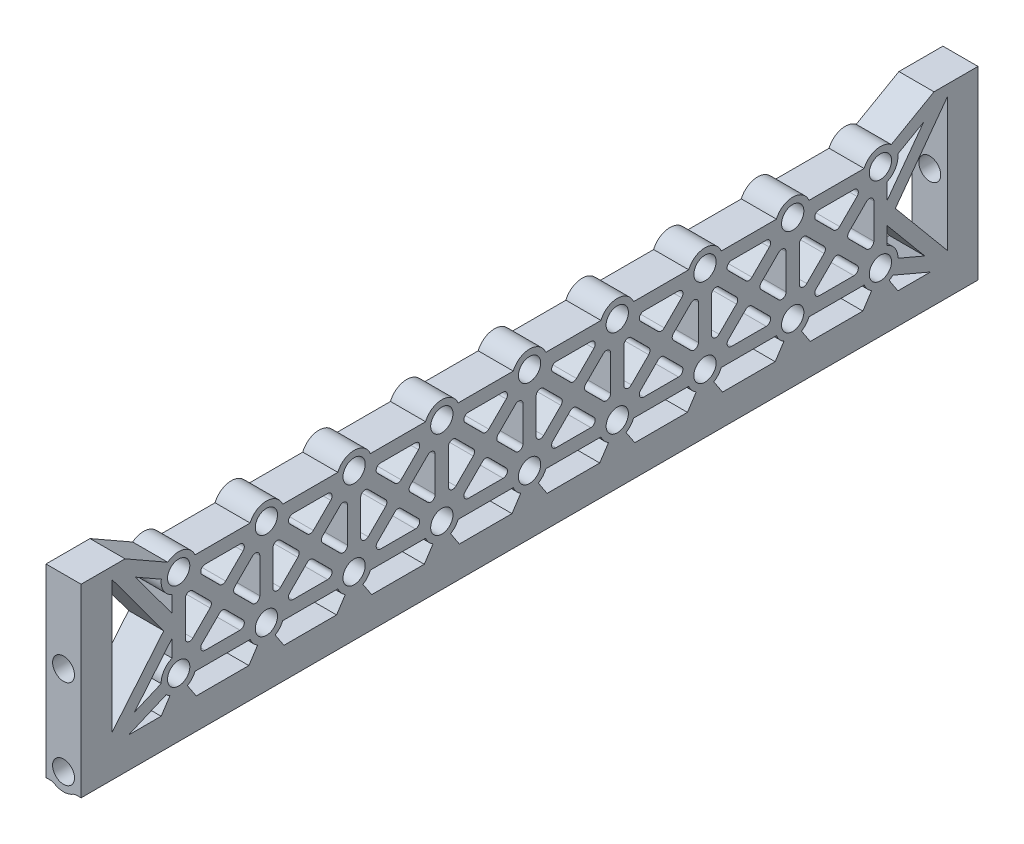
from build123d import *

# Parameters (mm, degrees)
SKETCH1_W                      = 204.5
SKETCH1_H                      = 42.185
BOSS_EXTRUDE1_DEPTH            = 8
F_5_0MM_DOWEL_HOLE1_AT_2_COUNT = 2
F_5_0MM_DOWEL_HOLE1_AT_2_PITCH = 20.325
SKETCH5_R                      = 4
SKETCH5_R_2                    = 2.5
BOSS_EXTRUDE2_DEPTH            = 10
FILLET1_R                      = 2
FILLET1_OF_MIRROR2_R           = 2
SKETCH6_W                      = 190.5
SKETCH6_H                      = 35.185
SKETCH6_R                      = 4
SKETCH6_R_2                    = 2.54
CUT_EXTRUDE1_DEPTH             = 9
BOSS_EXTRUDE3_DEPTH            = 8
LPATTERN1_COUNT                = 8
LPATTERN1_PITCH                = 20
BOSS_EXTRUDE4_DEPTH            = 8
BOSS_EXTRUDE5_DEPTH            = 8
LPATTERN2_COUNT                = 9
LPATTERN2_PITCH                = 20


with BuildPart() as part:
    # Sketch1 → Boss-Extrude1 (new body)
    with BuildSketch(Plane(origin=(218.75, 0, 0), x_dir=(0, 0, -1), z_dir=(1, 0, 0))):
        with Locations((0, 16.0925)):
            Rectangle(SKETCH1_W, SKETCH1_H)
    extrude(amount=-BOSS_EXTRUDE1_DEPTH)

    # Sketch3 → Ø5.0mm Dowel Hole1 (revolve, cut)
    with BuildSketch(Plane(origin=(214.75, 18.5, -102.25), x_dir=(0, 1, 0), z_dir=(1, 0, 0))):
        Polygon((0, 0), (0, 11.502151548), (2.5, 10), (2.5, 0), align=None)
    f_5_0mm_dowel_hole1 = revolve(axis=Axis((214.75, 18.5, -108.6), (0, 0, 1)), mode=Mode.SUBTRACT)

    # Ø5.0mm Dowel Hole1 at 2: Ø5.0mm Dowel Hole1 ×2
    with Locations(*[(0, -i * F_5_0MM_DOWEL_HOLE1_AT_2_PITCH, 0) for i in range(1, F_5_0MM_DOWEL_HOLE1_AT_2_COUNT)]):
        add(f_5_0mm_dowel_hole1, mode=Mode.SUBTRACT)

    # Sketch5 → Boss-Extrude2 (add)
    with BuildSketch(Plane(origin=(0, 0, -102.25), x_dir=(-1, 0, 0), z_dir=(0, 0, -1))):
        with Locations((-214.75, -1.825)):
            Circle(SKETCH5_R)
        with Locations((-214.75, -1.825)):
            Circle(SKETCH5_R_2, mode=Mode.SUBTRACT)
    boss_extrude2 = extrude(amount=-BOSS_EXTRUDE2_DEPTH)

    # Fillet1
    fillet1_edges = [part.edges().sort_by_distance(p)[0] for p in [
        (212.317023428, -5, -97.25),
        (217.182976572, -5, -97.25),
    ]]
    fillet(fillet1_edges, radius=FILLET1_R)

    # Mirror2: Boss-Extrude2, Ø5.0mm Dowel Hole1 across plane
    add(boss_extrude2.mirror(Plane.XY))
    add(f_5_0mm_dowel_hole1.mirror(Plane.XY), mode=Mode.SUBTRACT)

    # Mirror2 copy 1 sketch → Mirror2 copy 1 (revolve, cut)
    with BuildSketch(Plane(origin=(214.75, -1.825, 102.25), x_dir=(0, 1, 0), z_dir=(1, 0, 0))):
        Polygon((0, 0), (0, -11.502151548), (2.5, -10), (2.5, 0), align=None)
    revolve(axis=Axis((214.75, -1.825, 108.6), (0, 0, 1)), mode=Mode.SUBTRACT)

    # Fillet1 of Mirror2
    fillet1_of_mirror2_edges = [part.edges().sort_by_distance(p)[0] for p in [
        (212.317023428, -5, 97.25),
        (217.182976572, -5, 97.25),
    ]]
    fillet(fillet1_of_mirror2_edges, radius=FILLET1_OF_MIRROR2_R)

    # Sketch6 → Cut-Extrude1 (cut, through all)
    with BuildSketch(Plane(origin=(218.75, 0, 0), x_dir=(0, 0, -1), z_dir=(1, 0, 0))):
        with Locations((0, 19.5925)):
            Rectangle(SKETCH6_W, SKETCH6_H)
        with Locations((80, 28.5)):
            Circle(SKETCH6_R, mode=Mode.SUBTRACT)
        with Locations((60, 28.5)):
            Circle(SKETCH6_R, mode=Mode.SUBTRACT)
        with Locations((40, 28.5)):
            Circle(SKETCH6_R, mode=Mode.SUBTRACT)
        with Locations((20, 28.5)):
            Circle(SKETCH6_R, mode=Mode.SUBTRACT)
        with Locations((0, 28.5)):
            Circle(SKETCH6_R, mode=Mode.SUBTRACT)
        with Locations((-20, 28.5)):
            Circle(SKETCH6_R, mode=Mode.SUBTRACT)
        with Locations((-40, 28.5)):
            Circle(SKETCH6_R, mode=Mode.SUBTRACT)
        with Locations((-60, 28.5)):
            Circle(SKETCH6_R, mode=Mode.SUBTRACT)
        with Locations((-80, 28.5)):
            Circle(SKETCH6_R, mode=Mode.SUBTRACT)
        with Locations((-80, 8.5)):
            Circle(SKETCH6_R, mode=Mode.SUBTRACT)
        with Locations((-60, 8.5)):
            Circle(SKETCH6_R, mode=Mode.SUBTRACT)
        with Locations((-40, 8.5)):
            Circle(SKETCH6_R, mode=Mode.SUBTRACT)
        with Locations((-20, 8.5)):
            Circle(SKETCH6_R, mode=Mode.SUBTRACT)
        with Locations((0, 8.5)):
            Circle(SKETCH6_R, mode=Mode.SUBTRACT)
        with Locations((20, 8.5)):
            Circle(SKETCH6_R, mode=Mode.SUBTRACT)
        with Locations((40, 8.5)):
            Circle(SKETCH6_R, mode=Mode.SUBTRACT)
        with Locations((60, 8.5)):
            Circle(SKETCH6_R, mode=Mode.SUBTRACT)
        with Locations((80, 8.5)):
            Circle(SKETCH6_R, mode=Mode.SUBTRACT)
        with Locations((-80, 28.5)):
            Circle(SKETCH6_R_2)
        with Locations((80, 28.5)):
            Circle(SKETCH6_R_2)
        with Locations((-60, 28.5)):
            Circle(SKETCH6_R_2)
        with Locations((60, 28.5)):
            Circle(SKETCH6_R_2)
        with Locations((-40, 28.5)):
            Circle(SKETCH6_R_2)
        with Locations((40, 28.5)):
            Circle(SKETCH6_R_2)
        with Locations((-20, 28.5)):
            Circle(SKETCH6_R_2)
        with Locations((20, 28.5)):
            Circle(SKETCH6_R_2)
        with Locations((0, 28.5)):
            Circle(SKETCH6_R_2)
        with Locations((20, 8.5)):
            Circle(SKETCH6_R_2)
        with Locations((40, 8.5)):
            Circle(SKETCH6_R_2)
        with Locations((60, 8.5)):
            Circle(SKETCH6_R_2)
        with Locations((80, 8.5)):
            Circle(SKETCH6_R_2)
        with Locations((0, 8.5)):
            Circle(SKETCH6_R_2)
        with Locations((-80, 8.5)):
            Circle(SKETCH6_R_2)
        with Locations((-60, 8.5)):
            Circle(SKETCH6_R_2)
        with Locations((-40, 8.5)):
            Circle(SKETCH6_R_2)
        with Locations((-20, 8.5)):
            Circle(SKETCH6_R_2)
    extrude(amount=-CUT_EXTRUDE1_DEPTH, mode=Mode.SUBTRACT)

    # Sketch7 → Boss-Extrude3 (add)
    with BuildSketch(Plane(origin=(218.75, 0, 0), x_dir=(0, 0, -1), z_dir=(1, 0, 0))):
        with BuildLine():
            Line((-76.291900756, 30), (-63.708099244, 30))
            ThreePointArc((-63.708099244, 30), (-62.828427125, 25.671572875), (-58.5, 24.791900756))
            Line((-58.5, 24.791900756), (-58.5, 12.208099244))
            ThreePointArc((-58.5, 12.208099244), (-62.828427125, 11.328427125), (-63.708099244, 7))
            Line((-63.708099244, 7), (-76.291900756, 7))
            ThreePointArc((-76.291900756, 7), (-77.171572875, 11.328427125), (-81.5, 12.208099244))
            Line((-81.5, 12.208099244), (-81.5, 24.791900756))
            ThreePointArc((-81.5, 24.791900756), (-77.171572875, 25.671572875), (-76.291900756, 30))
        make_face()
        with BuildLine():
            Line((-74.671572875, 25.292893219), (-70.707106781, 21.328427125))
            ThreePointArc((-70.707106781, 21.328427125), (-70, 21.035533906), (-69.292893219, 21.328427125))
            Line((-69.292893219, 21.328427125), (-65.328427125, 25.292893219))
            ThreePointArc((-65.328427125, 25.292893219), (-65.111654373, 26.382683432), (-66.035533906, 27))
            Line((-66.035533906, 27), (-73.964466094, 27))
            ThreePointArc((-73.964466094, 27), (-74.888345627, 26.382683432), (-74.671572875, 25.292893219))
        make_face(mode=Mode.SUBTRACT)
        with BuildLine():
            Line((-61.5, 22.464466094), (-61.5, 14.535533906))
            ThreePointArc((-61.5, 14.535533906), (-62.117316568, 13.611654373), (-63.207106781, 13.828427125))
            Line((-63.207106781, 13.828427125), (-67.171572875, 17.792893219))
            ThreePointArc((-67.171572875, 17.792893219), (-67.464466094, 18.5), (-67.171572875, 19.207106781))
            Line((-67.171572875, 19.207106781), (-63.207106781, 23.171572875))
            ThreePointArc((-63.207106781, 23.171572875), (-62.117316568, 23.388345627), (-61.5, 22.464466094))
        make_face(mode=Mode.SUBTRACT)
        with BuildLine():
            Line((-66.035533906, 10), (-73.964466094, 10))
            ThreePointArc((-73.964466094, 10), (-74.888345627, 10.617316568), (-74.671572875, 11.707106781))
            Line((-74.671572875, 11.707106781), (-70.707106781, 15.671572875))
            ThreePointArc((-70.707106781, 15.671572875), (-70, 15.964466094), (-69.292893219, 15.671572875))
            Line((-69.292893219, 15.671572875), (-65.328427125, 11.707106781))
            ThreePointArc((-65.328427125, 11.707106781), (-65.111654373, 10.617316568), (-66.035533906, 10))
        make_face(mode=Mode.SUBTRACT)
        with BuildLine():
            Line((-78.5, 14.535533906), (-78.5, 22.464466094))
            ThreePointArc((-78.5, 22.464466094), (-77.882683432, 23.388345627), (-76.792893219, 23.171572875))
            Line((-76.792893219, 23.171572875), (-72.828427125, 19.207106781))
            ThreePointArc((-72.828427125, 19.207106781), (-72.535533906, 18.5), (-72.828427125, 17.792893219))
            Line((-72.828427125, 17.792893219), (-76.792893219, 13.828427125))
            ThreePointArc((-76.792893219, 13.828427125), (-77.882683432, 13.611654373), (-78.5, 14.535533906))
        make_face(mode=Mode.SUBTRACT)
    boss_extrude3 = extrude(amount=-BOSS_EXTRUDE3_DEPTH)

    # LPattern1: Boss-Extrude3 ×8
    with Locations(*[(0, 0, -i * LPATTERN1_PITCH) for i in range(1, LPATTERN1_COUNT)]):
        add(boss_extrude3)

    # Sketch8 → Boss-Extrude4 (add)
    with BuildSketch(Plane(origin=(218.75, 0, 0), x_dir=(0, 0, -1), z_dir=(1, 0, 0))):
        with BuildLine():
            Line((-95.25, 37.185), (-95.25, 34.654204411))
            Line((-95.25, 34.654204411), (-83.404667309, 18.557474132))
            Line((-83.404667309, 18.557474132), (-95.25, 4.343074903))
            Line((-95.25, 4.343074903), (-95.25, 2))
            Line((-95.25, 2), (-91.424430081, 2))
            Line((-91.424430081, 2), (-82.823019101, 5.666175172))
            ThreePointArc((-82.823019101, 5.666175172), (-83.679693059, 6.931606237), (-83.999314423, 8.425944966))
            Line((-83.999314423, 8.425944966), (-90.114568073, 5.81944341))
            Line((-90.114568073, 5.81944341), (-81.5, 16.156925097))
            Line((-81.5, 16.156925097), (-81.5, 21.030795589))
            Line((-81.5, 21.030795589), (-89.857309247, 32.387619101))
            Line((-89.857309247, 32.387619101), (-83.964514558, 29.031624224))
            ThreePointArc((-83.964514558, 29.031624224), (-83.475844275, 30.479521805), (-82.479873205, 31.63850743))
            Line((-82.479873205, 31.63850743), (-92.218964937, 37.185))
            Line((-92.218964937, 37.185), (-95.25, 37.185))
        make_face()
    boss_extrude4 = extrude(amount=-BOSS_EXTRUDE4_DEPTH)

    # Mirror3: Boss-Extrude4 across plane
    add(boss_extrude4.mirror(Plane.XY))

    # Sketch9 → Boss-Extrude5 (add)
    with BuildSketch(Plane(origin=(218.75, 0, 0), x_dir=(0, 0, -1), z_dir=(1, 0, 0))):
        Polygon((-82, 5.035898385), (-78, 5.035898385), (-76, 2), (-84, 2), align=None)
    boss_extrude5 = extrude(amount=-BOSS_EXTRUDE5_DEPTH)

    # LPattern2: Boss-Extrude5 ×9
    with Locations(*[(0, 0, -i * LPATTERN2_PITCH) for i in range(1, LPATTERN2_COUNT)]):
        add(boss_extrude5)


solid = part.part
